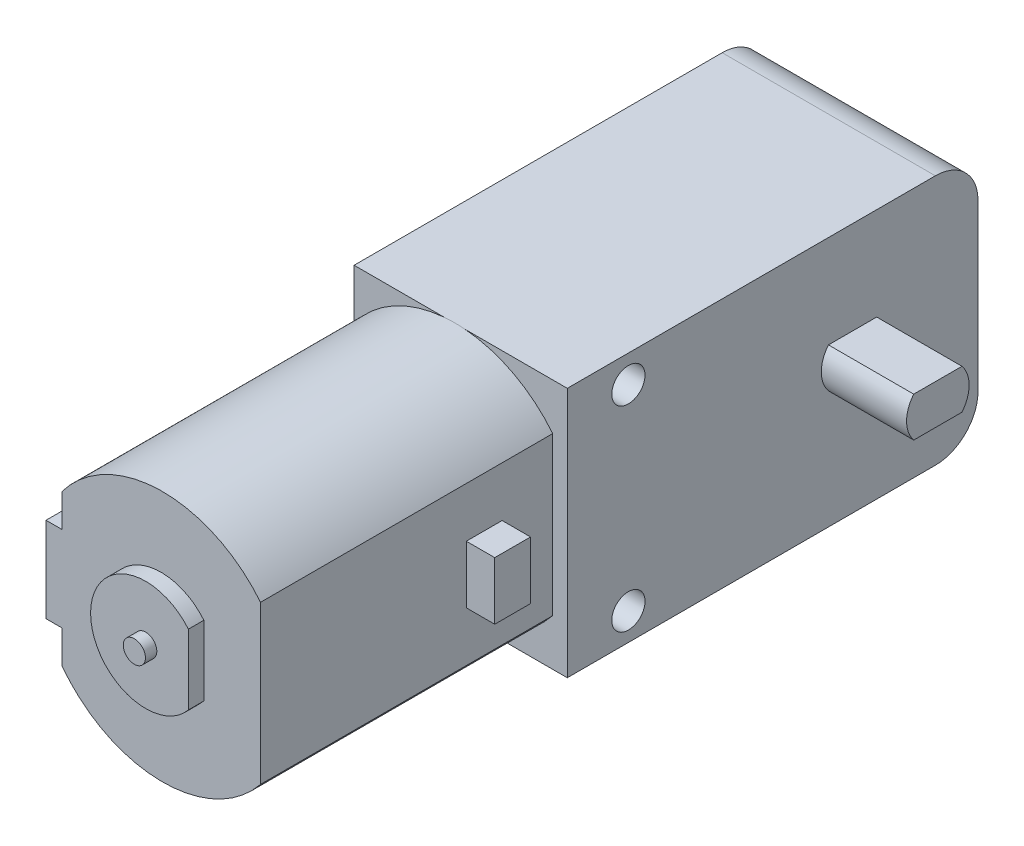
from build123d import *

# Parameters (mm, degrees)
SKETCH1_W           = 19.05
SKETCH1_H           = 36.703
BOSS_EXTRUDE1_DEPTH = 22.4028
BOSS_EXTRUDE2_DEPTH = 7.62
SKETCH3_R           = 1.4859
CUT_EXTRUDE1_DEPTH  = 20.05
FILLET1_R           = 3.81
SKETCH6_W           = 2.921
SKETCH6_H           = 5.0292
BOSS_EXTRUDE3_DEPTH = 4.8006
FILLET2_R           = 0.254
SKETCH7_R           = 1.4097
CUT_EXTRUDE2_DEPTH  = 11.4521
BOSS_EXTRUDE4_DEPTH = 26.1112
SKETCH11_W          = 3.2004
SKETCH11_H          = 5.1562
BOSS_EXTRUDE5_DEPTH = 2.54
SKETCH12_W          = 8.4582
SKETCH12_H          = 7.62
BOSS_EXTRUDE6_DEPTH = 1.4224
BOSS_EXTRUDE7_DEPTH = 1.3843
SKETCH14_R          = 0.9906
BOSS_EXTRUDE8_DEPTH = 1.016


with BuildPart() as part:
    # Sketch1 → Boss-Extrude1 (new body)
    with BuildSketch(Plane(origin=(0, 0, 0), x_dir=(1, 0, 0), z_dir=(0, 1, 0))):
        Rectangle(SKETCH1_W, SKETCH1_H)
    extrude(amount=BOSS_EXTRUDE1_DEPTH)

    # Sketch2 → Boss-Extrude2 (add)
    with BuildSketch(Plane(origin=(9.525, 0, 0), x_dir=(0, 0, -1), z_dir=(1, 0, 0))):
        with BuildLine():
            Line((9.297778198, 14.092814896), (4.98725526, 14.092814896))
            ThreePointArc((4.98725526, 14.092814896), (4.348516729, 12.314814896), (4.98725526, 10.536814896))
            Line((4.98725526, 10.536814896), (9.297778198, 10.536814896))
            ThreePointArc((9.297778198, 10.536814896), (9.771987831, 11.370189188), (9.936516729, 12.314814896))
            ThreePointArc((9.936516729, 12.314814896), (9.771987831, 13.259440604), (9.297778198, 14.092814896))
        make_face()
    extrude(amount=BOSS_EXTRUDE2_DEPTH)

    # Sketch3 → Cut-Extrude1 (cut, through all)
    with BuildSketch(Plane(origin=(9.525, 0, 0), x_dir=(0, 0, -1), z_dir=(1, 0, 0))):
        with Locations((-12.8905, 19.9517)):
            Circle(SKETCH3_R)
        with Locations((-12.8905, 2.4511)):
            Circle(SKETCH3_R)
    extrude(amount=-CUT_EXTRUDE1_DEPTH, mode=Mode.SUBTRACT)

    # Fillet1
    fillet1_edges = [part.edges().sort_by_distance(p)[0] for p in [
        (0, 22.4028, -18.3515),
        (0, 0, -18.3515),
    ]]
    fillet(fillet1_edges, radius=FILLET1_R)

    # Sketch6 → Boss-Extrude3 (add)
    with BuildSketch(Plane(origin=(0, 0, -18.3515), x_dir=(-1, 0, 0), z_dir=(0, 0, -1))):
        with Locations((0.5334, 11.2014)):
            Rectangle(SKETCH6_W, SKETCH6_H)
    extrude(amount=BOSS_EXTRUDE3_DEPTH)

    # Fillet2
    fillet2_edges = [part.edges().sort_by_distance(p)[0] for p in [
        (-0.5334, 8.6868, -18.3515),
        (-0.5334, 13.716, -18.3515),
        (-0.5334, 8.6868, -23.1521),
        (-0.5334, 13.716, -23.1521),
    ]]
    fillet(fillet2_edges, radius=FILLET2_R)

    # Sketch7 → Cut-Extrude2 (cut, through all)
    with BuildSketch(Plane(origin=(0.9271, 0, 0), x_dir=(0, 0, -1), z_dir=(1, 0, 0))):
        with Locations((20.7518, 11.2014)):
            Circle(SKETCH7_R)
    extrude(amount=-CUT_EXTRUDE2_DEPTH, mode=Mode.SUBTRACT)

    # Sketch8 → Boss-Extrude4 (add)
    with BuildSketch(Plane.XY.offset(18.3515)):
        with BuildLine():
            Line((-9.525, 17.9451), (-9.525, 4.4577))
            ThreePointArc((-9.525, 4.4577), (-0.724870396, -0.036468986), (8.22325, 4.155305974))
            Line((8.22325, 4.155305974), (8.22325, 18.247494026))
            ThreePointArc((8.22325, 18.247494026), (-0.724870396, 22.439268986), (-9.525, 17.9451))
        make_face()
    extrude(amount=BOSS_EXTRUDE4_DEPTH)

    # Sketch11 → Boss-Extrude5 (add)
    with BuildSketch(Plane.ZY.offset(9.525)):
        with Locations((24.4729, 11.2014)):
            Rectangle(SKETCH11_W, SKETCH11_H)
    boss_extrude5 = extrude(amount=BOSS_EXTRUDE5_DEPTH)

    # Mirror1: Boss-Extrude5 across plane
    add(boss_extrude5.mirror(Plane(origin=(-0.650875, 0, 0), x_dir=(0, 0, 1), z_dir=(1, 0, 0))))

    # Sketch12 → Boss-Extrude6 (add)
    with BuildSketch(Plane.ZY.offset(9.525)):
        with Locations((40.2336, 11.2014)):
            Rectangle(SKETCH12_W, SKETCH12_H)
    extrude(amount=BOSS_EXTRUDE6_DEPTH)

    # Sketch13 → Boss-Extrude7 (add)
    with BuildSketch(Plane.XY.offset(44.4627)):
        with BuildLine():
            Line((3.159125, 8.076477319), (3.159125, 14.326322681))
            ThreePointArc((3.159125, 14.326322681), (-5.578475, 11.2014), (3.159125, 8.076477319))
        make_face()
    extrude(amount=BOSS_EXTRUDE7_DEPTH)

    # Sketch14 → Boss-Extrude8 (add)
    with BuildSketch(Plane.XY.offset(45.847)):
        with Locations((-0.650875, 11.2014)):
            Circle(SKETCH14_R)
    extrude(amount=BOSS_EXTRUDE8_DEPTH)


solid = part.part
